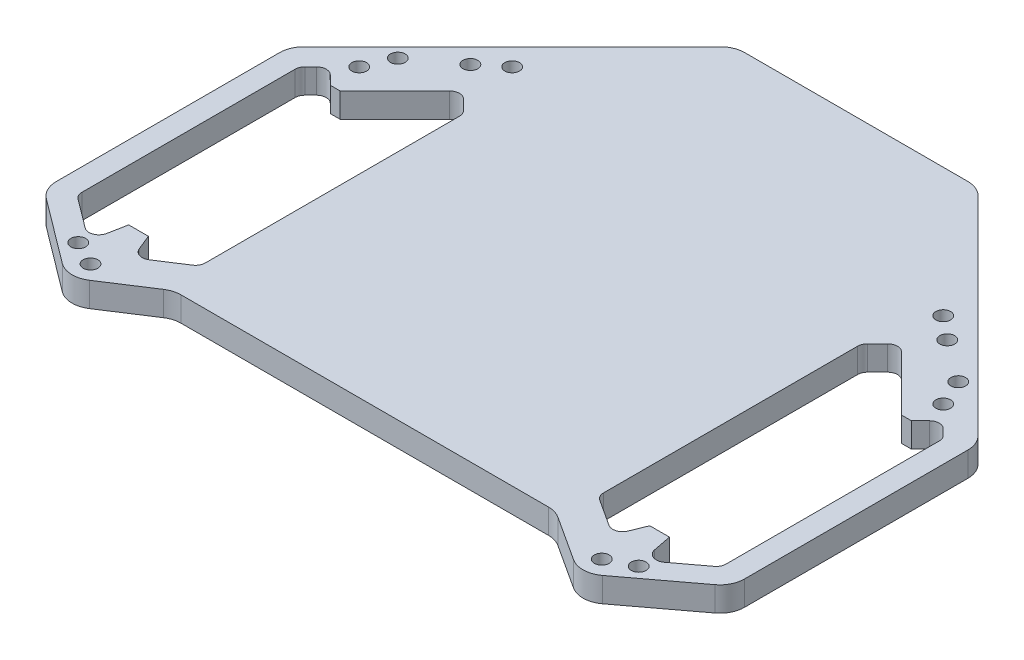
from build123d import *

# Parameters (mm, degrees)
SKETCH1_R            = 1.5
BOSS_EXTRUDE1_DEPTH  = 5
FILLET1_R            = 2
FILLET1_OF_MIRROR1_R = 2
SKETCH2_W            = 70
SKETCH2_H            = 97
CUT_EXTRUDE1_DEPTH   = 3
FILLET2_R            = 5


with BuildPart() as part:
    # Sketch1 → Boss-Extrude1 (new body)
    with BuildSketch(Plane(origin=(0, 0, 0), x_dir=(1, 0, 0), z_dir=(0, 1, 0))):
        Polygon((-52.164149312, -38.645247828), (-70, -25.247940817), (-70, 24.752308679), (-24.752308679, 70), (0, 70), (0, -30), (-38.851635079, -30), align=None)
        with Locations((-43.840620434, 43.840620434)):
            Circle(SKETCH1_R, mode=Mode.SUBTRACT)
        with Locations((-51.997575213, -33.767620171)):
            Circle(SKETCH1_R, mode=Mode.SUBTRACT)
        with Locations((-59.39696962, 28.284271247)):
            Circle(SKETCH1_R, mode=Mode.SUBTRACT)
        with Locations((-56.997575213, 33.73741674)):
            Circle(SKETCH1_R, mode=Mode.SUBTRACT)
        with Locations((-56.997575213, -31.26258326)):
            Circle(SKETCH1_R, mode=Mode.SUBTRACT)
        with Locations((-48.5, 40)):
            Circle(SKETCH1_R, mode=Mode.SUBTRACT)
        Polygon((-59.095959493, 22.1), (-57.095959493, 22.1), (-44.547727215, 34.648232278), (-40.5, 30.600505063), (-40.5, -23), (-48.796166422, -28.387593469), (-51, -23), (-55, -23), (-56.33662338, -29.883022962), (-65.5, -23), (-65.5, 22.181240867), (-62.33860018, 25.342640687), align=None, mode=Mode.SUBTRACT)
    boss_extrude1 = extrude(amount=BOSS_EXTRUDE1_DEPTH)

    # Fillet1
    fillet1_edges = [part.edges().sort_by_distance(p)[0] for p in [
        (-44.547727215, 2.5, -34.648232278),
        (-62.33860018, 2.5, -25.342640687),
        (-65.5, 2.5, -22.181240867),
        (-65.5, 2.5, 23),
        (-56.33662338, 2.5, 29.883022962),
        (-48.796166422, 2.5, 28.387593469),
        (-40.5, 2.5, 23),
        (-40.5, 2.5, -30.600505063),
    ]]
    fillet(fillet1_edges, radius=FILLET1_R)

    # Mirror1: Boss-Extrude1 across plane
    add(boss_extrude1.mirror(Plane(origin=(0, 5, 30), x_dir=(0, 0, 1), z_dir=(-1, 0, 0))))

    # Fillet1 of Mirror1
    fillet1_of_mirror1_edges = [part.edges().sort_by_distance(p)[0] for p in [
        (44.547727215, 2.5, -34.648232278),
        (62.33860018, 2.5, -25.342640687),
        (65.5, 2.5, -22.181240867),
        (65.5, 2.5, 23),
        (56.33662338, 2.5, 29.883022962),
        (48.796166422, 2.5, 28.387593469),
        (40.5, 2.5, 23),
        (40.5, 2.5, -30.600505063),
    ]]
    fillet(fillet1_of_mirror1_edges, radius=FILLET1_OF_MIRROR1_R)

    # Sketch2 → Cut-Extrude1 (cut)
    with BuildSketch(Plane(origin=(0, 0, 0), x_dir=(1, 0, 0), z_dir=(0, 1, 0))):
        with Locations((0, 21.5)):
            Rectangle(SKETCH2_W, SKETCH2_H)
    extrude(amount=CUT_EXTRUDE1_DEPTH, mode=Mode.SUBTRACT)

    # Fillet2
    fillet2_edges = [part.edges().sort_by_distance(p)[0] for p in [
        (-70, 2.5, -24.752308679),
        (-24.752308679, 4, -70),
        (-38.851635079, 2.5, 30),
        (-52.164149312, 2.5, 38.645247828),
        (-70, 2.5, 25.247940817),
        (70, 2.5, 25.247940817),
        (70, 2.5, -24.752308679),
        (24.752308679, 4, -70),
        (38.851635079, 2.5, 30),
        (52.164149312, 2.5, 38.645247828),
    ]]
    fillet(fillet2_edges, radius=FILLET2_R)


solid = part.part
